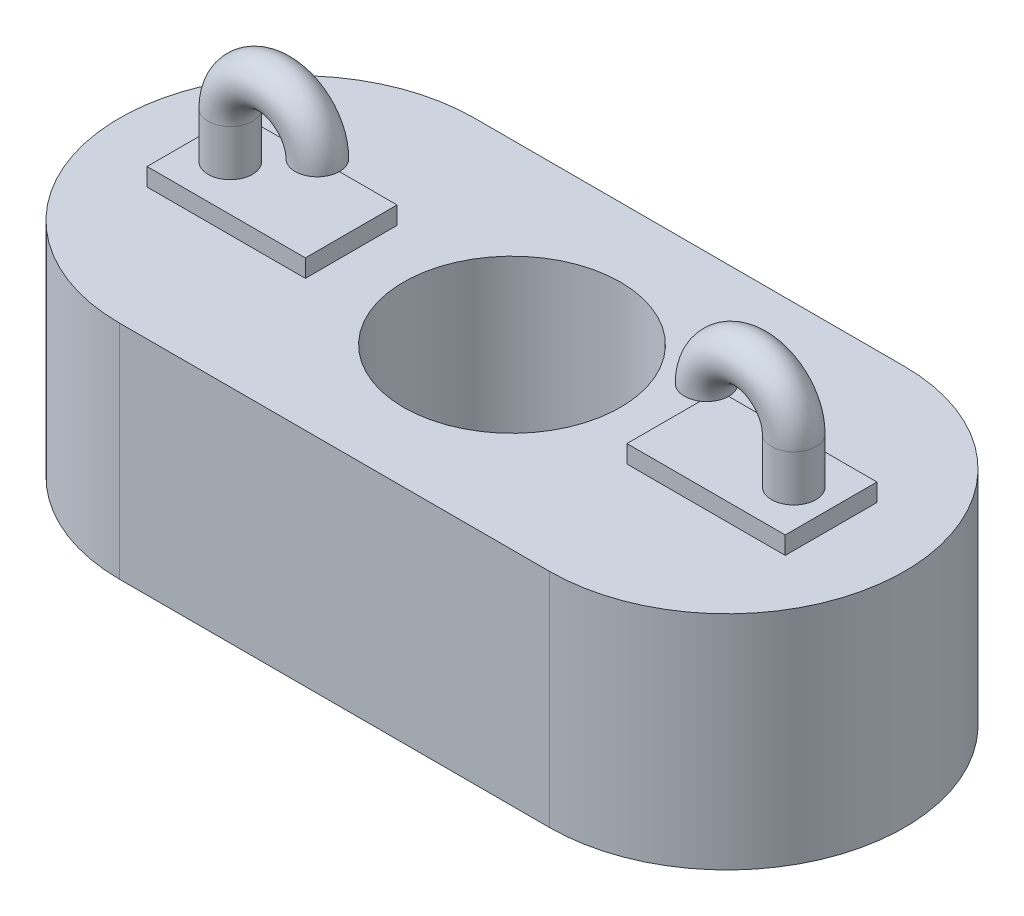
from build123d import *

# Parameters (mm, degrees)
SKETCH1_R           = 2.44543137
BOSS_EXTRUDE1_DEPTH = 5
SKETCH2_W           = 3.567027941
SKETCH2_H           = 2.066611426
BOSS_EXTRUDE2_DEPTH = 0.4
SWEEP2_PROFILE_R    = 0.5


with BuildPart() as part:
    # Sketch1 → Boss-Extrude1 (new body)
    with BuildSketch(Plane(origin=(0, 0, 0), x_dir=(1, 0, 0), z_dir=(0, 1, 0))):
        with BuildLine():
            Line((-4.846115072, 4), (4.846115072, 4))
            ThreePointArc((4.846115072, 4), (8.846115072, 0), (4.846115072, -4))
            Line((4.846115072, -4), (-4.846115072, -4))
            ThreePointArc((-4.846115072, -4), (-8.846115072, 0), (-4.846115072, 4))
        make_face()
        Circle(SKETCH1_R, mode=Mode.SUBTRACT)
    extrude(amount=BOSS_EXTRUDE1_DEPTH)

    # Sketch2 → Boss-Extrude2 (add)
    with BuildSketch(Plane(origin=(0, 5, 0), x_dir=(1, 0, 0), z_dir=(0, 1, 0))):
        with Locations((-5.407161402, 0)):
            Rectangle(SKETCH2_W, SKETCH2_H)
    boss_extrude2 = extrude(amount=BOSS_EXTRUDE2_DEPTH)

    # Sweep2: sweep along a path in Sketch3
    with BuildLine(Plane.XY) as sweep2_path:
        Line((-6.34863908, 5.4), (-6.34863908, 6.437017348))
        ThreePointArc((-6.34863908, 6.437017348), (-5.367322582, 7.418333845), (-4.386006084, 6.437017348))
    # Sweep2 profile (on start of the path) → Sweep2 (sweep)
    with BuildSketch(Plane(origin=(-6.34863908, 5.4, 0), x_dir=(0, 0, 1), z_dir=(0, 1, 0))):
        Circle(SWEEP2_PROFILE_R)
    sweep2 = sweep(path=sweep2_path.line)

    # Mirror1: Boss-Extrude2, Sweep2 across plane
    add(boss_extrude2.mirror(Plane(origin=(0, 0, 0), x_dir=(0, 0, 1), z_dir=(1, 0, 0))))
    add(sweep2.mirror(Plane(origin=(0, 0, 0), x_dir=(0, 0, 1), z_dir=(1, 0, 0))))


solid = part.part
